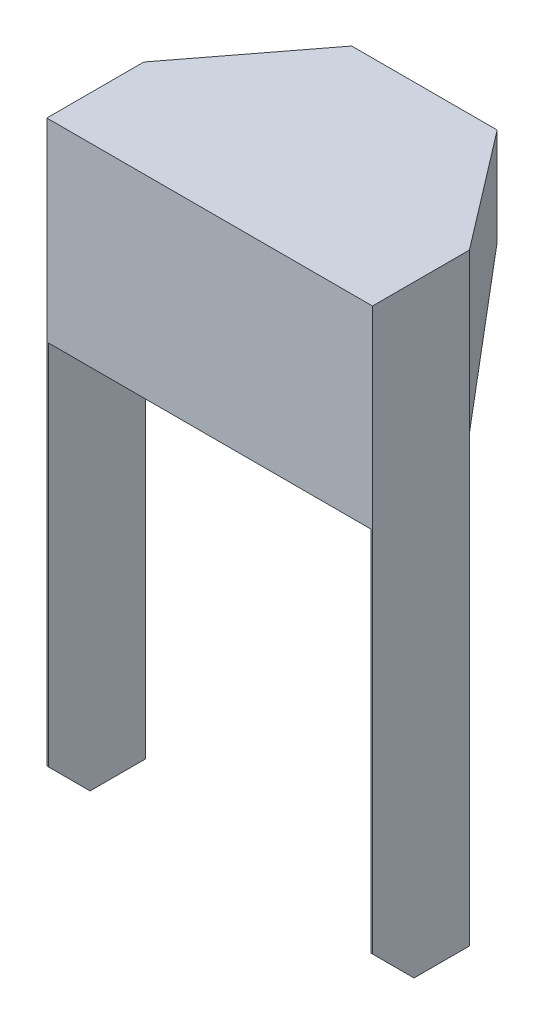
from build123d import *

# Parameters (mm, degrees)
BOSS_EXTRUDE1_DEPTH = 1.2
SKETCH2_W           = 70
SKETCH2_H           = 435
BOSS_EXTRUDE2_DEPTH = 1.2
BOSS_EXTRUDE3_DEPTH = 1.2
SKETCH4_W           = 52.5
SKETCH4_H           = 70
BOSS_EXTRUDE4_DEPTH = 1.2
CHAMFER1_SIZE       = 30
SKETCH6_W           = 117.5
SKETCH6_H           = 140
BOSS_EXTRUDE5_DEPTH = 1.2


with BuildPart() as part:
    # Sketch1 → Boss-Extrude1 (new body)
    with BuildSketch(Plane(origin=(0, 0, 0), x_dir=(1, 0, 0), z_dir=(0, 1, 0))):
        Polygon((0, 0), (0, 155), (-52.5, 155), (-117.5, 70), (-117.5, 0), align=None)
    extrude(amount=BOSS_EXTRUDE1_DEPTH)

    # Sketch2 → Boss-Extrude2 (add)
    with BuildSketch(Plane.ZY.offset(117.5)):
        with Locations((-35, -216.3)):
            Rectangle(SKETCH2_W, SKETCH2_H)
    extrude(amount=-BOSS_EXTRUDE2_DEPTH)

    # Sketch3 → Boss-Extrude3 (add)
    with BuildSketch(Plane(origin=(-107.920305677, 0, -82.527292576), x_dir=(-0.607450108, 0, 0.794357833), z_dir=(-0.794357833, 0, -0.607450108))):
        Polygon((-91.234333464, 1.2), (15.770339331, 1.2), (15.770339331, -113.122786709), (-91.234333464, -68.8), align=None)
    extrude(amount=-BOSS_EXTRUDE3_DEPTH)

    # Sketch4 → Boss-Extrude4 (add)
    with BuildSketch(Plane(origin=(0, 0, -155), x_dir=(-1, 0, 0), z_dir=(0, 0, -1))):
        with Locations((26.25, -33.8)):
            Rectangle(SKETCH4_W, SKETCH4_H)
    extrude(amount=-BOSS_EXTRUDE4_DEPTH)

    # Chamfer1
    chamfer1_edges = [part.edges().sort_by_distance(p)[0] for p in [
        (-116.9, -433.8, 0),
    ]]
    chamfer(chamfer1_edges, length=CHAMFER1_SIZE)

    # Sketch6 → Boss-Extrude5 (add)
    with BuildSketch(Plane.XY):
        with Locations((-58.75, -68.8)):
            Rectangle(SKETCH6_W, SKETCH6_H)
    extrude(amount=-BOSS_EXTRUDE5_DEPTH)

    # Mirror1: part across face


with BuildPart() as part_1:
    add(part.part)
    add(part.part.mirror(Plane(origin=(0, -32.836293436, -62.654440154), x_dir=(0, 0, 1), z_dir=(1, 0, 0))))


solid = part_1.part
